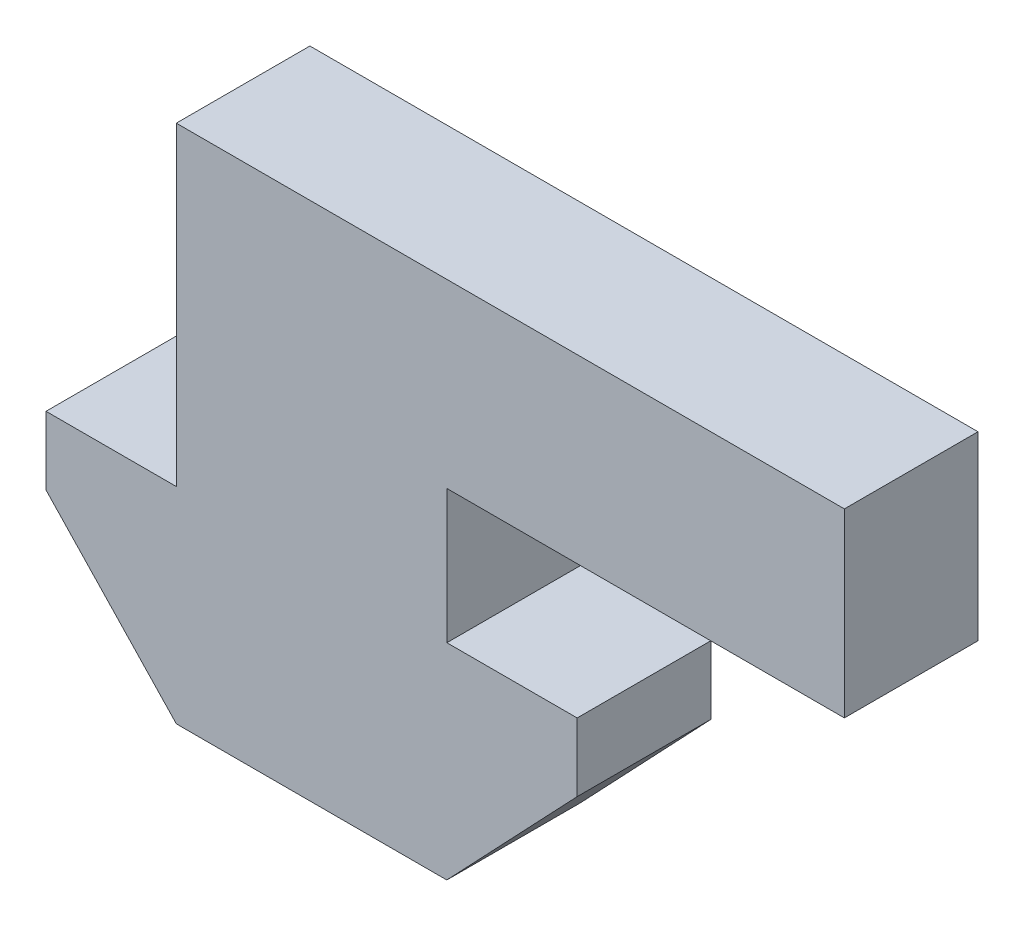
from build123d import *

# Parameters (mm, degrees)
BOSS_EXTRUDE1_DEPTH = 4


with BuildPart() as part:
    # Sketch1 → Boss-Extrude1 (new body)
    with BuildSketch(Plane.XY):
        Polygon((-7.95, -2.04), (-7.95, 0), (7.95, 0), (7.95, -2.04), (4.048, -6.152414984), (-4.048, -6.152414984), align=None)
        Polygon((-4.05, 9.42), (-4.05, 0), (4.05, 0), (4.05, 4), (15.95, 4), (15.95, 9.42), align=None)
    extrude(amount=BOSS_EXTRUDE1_DEPTH)


solid = part.part
